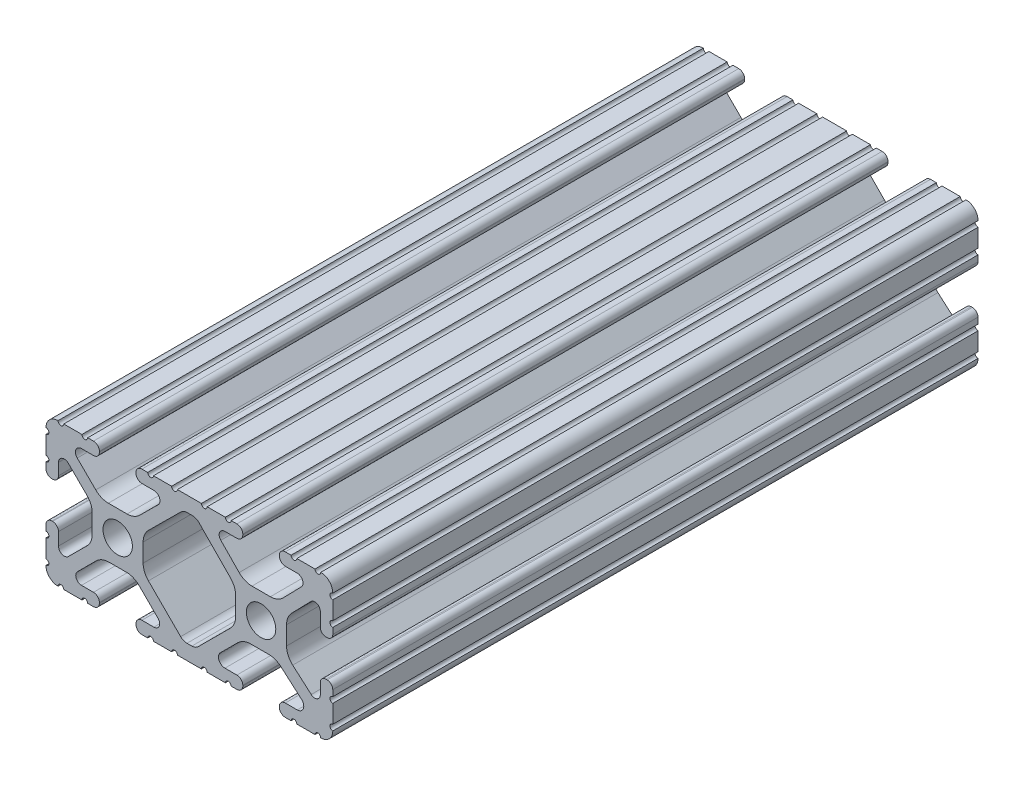
from build123d import *

# Parameters (mm, degrees)
SKETCH1_R           = 2.6035
BOSS_EXTRUDE1_DEPTH = 57.15


with BuildPart() as part:
    # Sketch1 → Boss-Extrude1 (new body, symmetric)
    with BuildSketch(Plane.XY):
        with BuildLine():
            Line((18.01710265, 12.7), (16.98745015, 12.7))
            ThreePointArc((16.98745015, 12.7), (16.245730386, 12.392769614), (15.9385, 11.65104985))
            Line((15.9385, 11.65104985), (15.9385, 11.53922))
            ThreePointArc((15.9385, 11.53922), (16.245750844, 10.797450844), (16.98752, 10.4902))
            Line((16.98752, 10.4902), (19.116384363, 10.4902))
            ThreePointArc((19.116384363, 10.4902), (20.052502933, 9.869096983), (19.844087081, 8.765172272))
            Line((19.844087081, 8.765172272), (16.618993479, 5.455112286))
            ThreePointArc((16.618993479, 5.455112286), (15.578994274, 4.745442459), (14.344932584, 4.4958))
            Line((14.344932584, 4.4958), (11.083317835, 4.4958))
            ThreePointArc((11.083317835, 4.4958), (9.854330953, 4.743306833), (8.816955189, 5.447238587))
            Line((8.816955189, 5.447238587), (5.564154119, 8.762652677))
            ThreePointArc((5.564154119, 8.762652677), (5.352591412, 9.867473037), (6.289393385, 10.4902))
            Line((6.289393385, 10.4902), (8.41248, 10.4902))
            ThreePointArc((8.41248, 10.4902), (9.154249156, 10.797450844), (9.4615, 11.53922))
            Line((9.4615, 11.53922), (9.4615, 11.65104985))
            ThreePointArc((9.4615, 11.65104985), (9.154269614, 12.392769614), (8.41254985, 12.7))
            Line((8.41254985, 12.7), (7.38288465, 12.7))
            ThreePointArc((7.38288465, 12.7), (6.87488465, 12.192), (6.36688465, 12.7))
            Line((6.36688465, 12.7), (3.14958095, 12.7))
            ThreePointArc((3.14958095, 12.7), (2.64158095, 12.192), (2.13358095, 12.7))
            Line((2.13358095, 12.7), (-2.13358095, 12.7))
            ThreePointArc((-2.13358095, 12.7), (-2.64158095, 12.192), (-3.14958095, 12.7))
            Line((-3.14958095, 12.7), (-6.36689735, 12.7))
            ThreePointArc((-6.36689735, 12.7), (-6.87489735, 12.192), (-7.38289735, 12.7))
            Line((-7.38289735, 12.7), (-8.41254985, 12.7))
            ThreePointArc((-8.41254985, 12.7), (-9.154269614, 12.392769614), (-9.4615, 11.65104985))
            Line((-9.4615, 11.65104985), (-9.4615, 11.53922))
            ThreePointArc((-9.4615, 11.53922), (-9.154249156, 10.797450844), (-8.41248, 10.4902))
            Line((-8.41248, 10.4902), (-6.283641037, 10.4902))
            ThreePointArc((-6.283641037, 10.4902), (-5.297291557, 9.829633109), (-5.532576693, 8.666071843))
            Line((-5.532576693, 8.666071843), (-8.809985098, 5.416263103))
            ThreePointArc((-8.809985098, 5.416263103), (-9.836720513, 4.734920264), (-11.045536121, 4.4958))
            Line((-11.045536121, 4.4958), (-14.354463879, 4.4958))
            ThreePointArc((-14.354463879, 4.4958), (-15.563279487, 4.734920264), (-16.590014902, 5.416263103))
            Line((-16.590014902, 5.416263103), (-19.867423307, 8.666071843))
            ThreePointArc((-19.867423307, 8.666071843), (-20.102708443, 9.829633109), (-19.116358963, 10.4902))
            Line((-19.116358963, 10.4902), (-16.98752, 10.4902))
            ThreePointArc((-16.98752, 10.4902), (-16.245750844, 10.797450844), (-15.9385, 11.53922))
            Line((-15.9385, 11.53922), (-15.9385, 11.65104985))
            ThreePointArc((-15.9385, 11.65104985), (-16.245730386, 12.392769614), (-16.98745015, 12.7))
            Line((-16.98745015, 12.7), (-18.01711535, 12.7))
            ThreePointArc((-18.01711535, 12.7), (-18.52511535, 12.192), (-19.03311535, 12.7))
            Line((-19.03311535, 12.7), (-22.2504, 12.7))
            ThreePointArc((-22.2504, 12.7), (-22.758323491, 12.192000006), (-23.266399977, 12.699846982))
            ThreePointArc((-23.266399977, 12.699846982), (-24.782522516, 12.082522516), (-25.399846982, 10.566399977))
            ThreePointArc((-25.399846982, 10.566399977), (-24.892000006, 10.058323491), (-25.4, 9.5504))
            Line((-25.4, 9.5504), (-25.4, 6.3330836))
            ThreePointArc((-25.4, 6.3330836), (-24.892, 5.8250836), (-25.4, 5.3170836))
            Line((-25.4, 5.3170836), (-25.4, 4.237520184))
            ThreePointArc((-25.4, 4.237520184), (-25.107393763, 3.531106237), (-24.400979816, 3.2385))
            Line((-24.400979816, 3.2385), (-24.23922, 3.2385))
            ThreePointArc((-24.23922, 3.2385), (-23.497450844, 3.545750844), (-23.1902, 4.28752))
            Line((-23.1902, 4.28752), (-23.1902, 6.334741132))
            ThreePointArc((-23.1902, 6.334741132), (-22.556026952, 7.286023527), (-21.434002553, 7.066535717))
            Line((-21.434002553, 7.066535717), (-18.147950853, 3.808156468))
            ThreePointArc((-18.147950853, 3.808156468), (-17.452759693, 2.774838327), (-17.208501877, 1.553619571))
            Line((-17.208501877, 1.553619571), (-17.208501877, -1.695179196))
            ThreePointArc((-17.208501877, -1.695179196), (-17.450738657, -2.911536421), (-18.140486065, -3.942289578))
            Line((-18.140486065, -3.942289578), (-21.431579576, -7.227386226))
            ThreePointArc((-21.431579576, -7.227386226), (-22.55444896, -7.449940594), (-23.1902, -6.498002195))
            Line((-23.1902, -6.498002195), (-23.1902, -4.28752))
            ThreePointArc((-23.1902, -4.28752), (-23.497450844, -3.545750844), (-24.23922, -3.2385))
            Line((-24.23922, -3.2385), (-24.35098, -3.2385))
            ThreePointArc((-24.35098, -3.2385), (-25.092749156, -3.545750844), (-25.4, -4.28752))
            Line((-25.4, -4.28752), (-25.4, -5.3171344))
            ThreePointArc((-25.4, -5.3171344), (-24.892, -5.8251344), (-25.4, -6.3331344))
            Line((-25.4, -6.3331344), (-25.4, -9.5504))
            ThreePointArc((-25.4, -9.5504), (-24.892000006, -10.058323491), (-25.399846982, -10.566399977))
            ThreePointArc((-25.399846982, -10.566399977), (-24.782522516, -12.082522516), (-23.266399977, -12.699846982))
            ThreePointArc((-23.266399977, -12.699846982), (-22.758323491, -12.192000006), (-22.2504, -12.7))
            Line((-22.2504, -12.7), (-19.03308995, -12.7))
            ThreePointArc((-19.03308995, -12.7), (-18.52508995, -12.192), (-18.01708995, -12.7))
            Line((-18.01708995, -12.7), (-16.9874692, -12.7))
            ThreePointArc((-16.9874692, -12.7), (-16.245700044, -12.392749156), (-15.9384492, -11.65098))
            Line((-15.9384492, -11.65098), (-15.9384492, -11.53922))
            ThreePointArc((-15.9384492, -11.53922), (-16.245700044, -10.797450844), (-16.9874692, -10.4902))
            Line((-16.9874692, -10.4902), (-19.116358963, -10.4902))
            ThreePointArc((-19.116358963, -10.4902), (-20.055197748, -9.862578342), (-19.834124023, -8.755124678))
            Line((-19.834124023, -8.755124678), (-16.49660751, -5.423689618))
            ThreePointArc((-16.49660751, -5.423689618), (-15.467274017, -4.736928798), (-14.253591699, -4.4958))
            Line((-14.253591699, -4.4958), (-11.146408301, -4.4958))
            ThreePointArc((-11.146408301, -4.4958), (-9.932725983, -4.736928798), (-8.90339249, -5.423689618))
            Line((-8.90339249, -5.423689618), (-5.565875977, -8.755124678))
            ThreePointArc((-5.565875977, -8.755124678), (-5.344802252, -9.862578342), (-6.283641037, -10.4902))
            Line((-6.283641037, -10.4902), (-8.4125308, -10.4902))
            ThreePointArc((-8.4125308, -10.4902), (-9.154299956, -10.797450844), (-9.4615508, -11.53922))
            Line((-9.4615508, -11.53922), (-9.4615508, -11.65098))
            ThreePointArc((-9.4615508, -11.65098), (-9.154299956, -12.392749156), (-8.4125308, -12.7))
            Line((-8.4125308, -12.7), (-7.38287195, -12.7))
            ThreePointArc((-7.38287195, -12.7), (-6.87487195, -12.192), (-6.36687195, -12.7))
            Line((-6.36687195, -12.7), (-3.14960635, -12.7))
            ThreePointArc((-3.14960635, -12.7), (-2.64160635, -12.192), (-2.13360635, -12.7))
            Line((-2.13360635, -12.7), (2.13360635, -12.7))
            ThreePointArc((2.13360635, -12.7), (2.64159365, -12.1920127), (3.14958095, -12.7))
            Line((3.14958095, -12.7), (6.36691005, -12.7))
            ThreePointArc((6.36691005, -12.7), (6.87491005, -12.192), (7.38291005, -12.7))
            Line((7.38291005, -12.7), (8.4125308, -12.7))
            ThreePointArc((8.4125308, -12.7), (9.154299956, -12.392749156), (9.4615508, -11.65098))
            Line((9.4615508, -11.65098), (9.4615508, -11.53922))
            ThreePointArc((9.4615508, -11.53922), (9.154299956, -10.797450844), (8.4125308, -10.4902))
            Line((8.4125308, -10.4902), (6.289393385, -10.4902))
            ThreePointArc((6.289393385, -10.4902), (5.231590322, -9.783049717), (5.480677245, -8.535265862))
            Line((5.480677245, -8.535265862), (8.597933595, -5.423689618))
            ThreePointArc((8.597933595, -5.423689618), (9.627267088, -4.736928798), (10.840949406, -4.4958))
            Line((10.840949406, -4.4958), (14.102564155, -4.4958))
            ThreePointArc((14.102564155, -4.4958), (15.215927525, -4.697410182), (16.187895372, -5.276636531))
            Line((16.187895372, -5.276636531), (19.868247549, -8.482246082))
            ThreePointArc((19.868247549, -8.482246082), (20.188435806, -9.746879864), (19.116384363, -10.4902))
            Line((19.116384363, -10.4902), (16.9874692, -10.4902))
            ThreePointArc((16.9874692, -10.4902), (16.245700044, -10.797450844), (15.9384492, -11.53922))
            Line((15.9384492, -11.53922), (15.9384492, -11.65098))
            ThreePointArc((15.9384492, -11.65098), (16.245700044, -12.392749156), (16.9874692, -12.7))
            Line((16.9874692, -12.7), (18.01710265, -12.7))
            ThreePointArc((18.01710265, -12.7), (18.52510265, -12.192), (19.03310265, -12.7))
            Line((19.03310265, -12.7), (22.2504, -12.7))
            ThreePointArc((22.2504, -12.7), (22.758323491, -12.192000006), (23.266399977, -12.699846982))
            ThreePointArc((23.266399977, -12.699846982), (24.782522516, -12.082522516), (25.399846982, -10.566399977))
            ThreePointArc((25.399846982, -10.566399977), (24.892000006, -10.058323492), (25.4, -9.550400001))
            Line((25.4, -9.550400001), (25.4, -6.333083592))
            ThreePointArc((25.4, -6.333083592), (24.892000001, -5.825083593), (25.4, -5.317083593))
            Line((25.4, -5.317083593), (25.4, -4.237520184))
            ThreePointArc((25.4, -4.237520184), (25.107393763, -3.531106237), (24.400979816, -3.2385))
            Line((24.400979816, -3.2385), (24.189220184, -3.2385))
            ThreePointArc((24.189220184, -3.2385), (23.482806237, -3.531106237), (23.1902, -4.237520184))
            Line((23.1902, -4.237520184), (23.1902, -6.155876159))
            ThreePointArc((23.1902, -6.155876159), (22.62232736, -7.038258539), (21.583974541, -6.886926384))
            Line((21.583974541, -6.886926384), (18.29817066, -4.024970844))
            ThreePointArc((18.29817066, -4.024970844), (17.493730985, -2.946044689), (17.208501877, -1.630807374))
            Line((17.208501877, -1.630807374), (17.208501877, 1.630807374))
            ThreePointArc((17.208501877, 1.630807374), (17.442348332, 2.82673414), (18.109440981, 3.846495088))
            Line((18.109440981, 3.846495088), (21.526346532, 7.353420386))
            ThreePointArc((21.526346532, 7.353420386), (22.585896263, 7.574939077), (23.1902, 6.676867167))
            Line((23.1902, 6.676867167), (23.1902, 4.237520184))
            ThreePointArc((23.1902, 4.237520184), (23.482806237, 3.531106237), (24.189220184, 3.2385))
            Line((24.189220184, 3.2385), (24.400979816, 3.2385))
            ThreePointArc((24.400979816, 3.2385), (25.107393763, 3.531106237), (25.4, 4.237520184))
            Line((25.4, 4.237520184), (25.4, 5.3170836))
            ThreePointArc((25.4, 5.3170836), (24.891949193, 5.825134407), (25.4, 6.333185215))
            Line((25.4, 6.333185215), (25.4, 9.550400015))
            ThreePointArc((25.4, 9.550400015), (24.892000013, 10.058323498), (25.399846982, 10.566399977))
            ThreePointArc((25.399846982, 10.566399977), (24.782522516, 12.082522516), (23.266399977, 12.699846982))
            ThreePointArc((23.266399977, 12.699846982), (22.758323491, 12.192000006), (22.2504, 12.7))
            Line((22.2504, 12.7), (19.03310265, 12.7))
            ThreePointArc((19.03310265, 12.7), (18.52510265, 12.192), (18.01710265, 12.7))
        make_face()
        with Locations((-12.7, 0)):
            Circle(SKETCH1_R, mode=Mode.SUBTRACT)
        with Locations((12.7, 0)):
            Circle(SKETCH1_R, mode=Mode.SUBTRACT)
        with BuildLine():
            Line((-7.259513935, -3.869413038), (-1.545748891, -9.572766749))
            ThreePointArc((-1.545748891, -9.572766749), (-1.035199478, -9.913400116), (-0.433213048, -10.033))
            Line((-0.433213048, -10.033), (0.433213048, -10.033))
            ThreePointArc((0.433213048, -10.033), (1.035199478, -9.913400116), (1.545748891, -9.572766749))
            Line((1.545748891, -9.572766749), (7.259513935, -3.869413038))
            ThreePointArc((7.259513935, -3.869413038), (7.949261343, -2.838659881), (8.191498123, -1.622302656))
            Line((8.191498123, -1.622302656), (8.191498123, 1.622302656))
            ThreePointArc((8.191498123, 1.622302656), (7.955573352, 2.823327967), (7.282860769, 3.845864069))
            Line((7.282860769, 3.845864069), (1.675572808, 9.561086461))
            ThreePointArc((1.675572808, 9.561086461), (1.161034429, 9.910236611), (0.551456936, 10.033))
            Line((0.551456936, 10.033), (-0.395199982, 10.033))
            ThreePointArc((-0.395199982, 10.033), (-0.994772524, 9.914396349), (-1.50403329, 9.576450301))
            Line((-1.50403329, 9.576450301), (-7.252049147, 3.876839553))
            ThreePointArc((-7.252049147, 3.876839553), (-7.947240307, 2.843521412), (-8.191498123, 1.622302656))
            Line((-8.191498123, 1.622302656), (-8.191498123, -1.622302656))
            ThreePointArc((-8.191498123, -1.622302656), (-7.949261343, -2.838659881), (-7.259513935, -3.869413038))
        make_face(mode=Mode.SUBTRACT)
    extrude(amount=BOSS_EXTRUDE1_DEPTH, both=True)


solid = part.part
